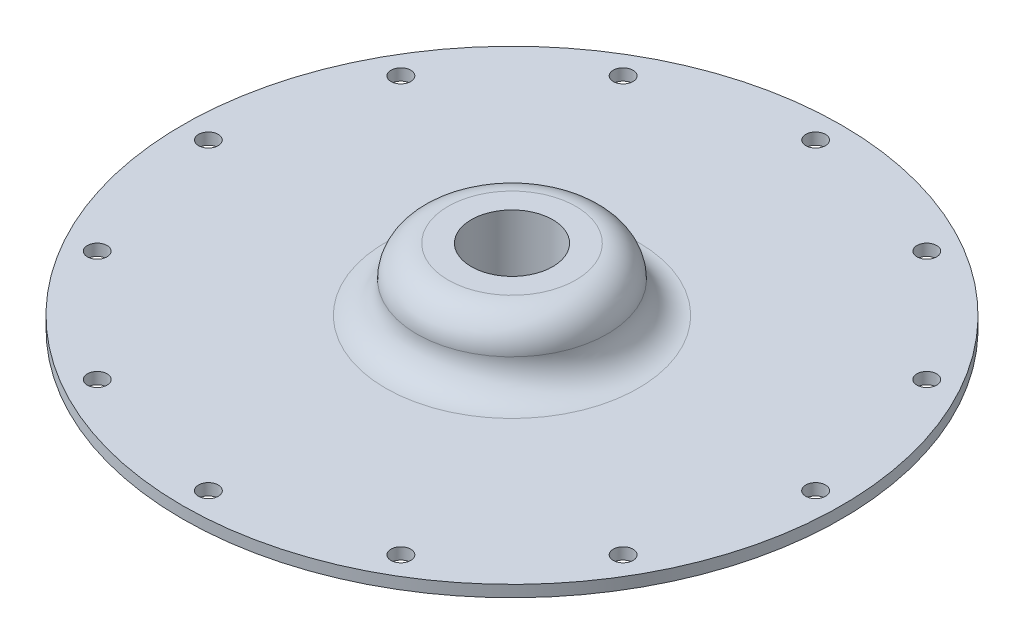
from build123d import *

# Parameters (mm, degrees)
F_36_0_1065_DIAMETER_HOLE1_D = 2.7051
CIRPATTERN1_COUNT            = 12


with BuildPart() as part:
    # Sketch1 → Revolve1 (revolve)
    with BuildSketch(Plane.XY):
        with BuildLine():
            Line((-45.212, 0), (-5.588, 0))
            Line((-5.588, 0), (-5.588, 10.16))
            Line((-5.588, 10.16), (-8.763, 10.16))
            ThreePointArc((-8.763, 10.16), (-11.793836441, 8.904586441), (-13.04925, 5.87375))
            ThreePointArc((-13.04925, 5.87375), (-14.304663559, 2.842913559), (-17.3355, 1.5875))
            Line((-17.3355, 1.5875), (-45.212, 1.5875))
            Line((-45.212, 1.5875), (-45.212, 0))
        make_face()
    revolve(axis=Axis((0, 55, 0), (0, -1, 0)))

    # #36 (0.1065) Diameter Hole1 (through all)
    with Locations(Plane(origin=(0, 0, 0), x_dir=(-1, 0, 0), z_dir=(0, -1, 0))):
        with Locations((41.656, 0)):
            f_36_0_1065_diameter_hole1 = Hole(F_36_0_1065_DIAMETER_HOLE1_D / 2)

    # CirPattern1: #36 (0.1065) Diameter Hole1 ×12 about axis
    cirpattern1_axis = Axis((0, 0, 0), (0, 1, 0))
    for i in range(1, CIRPATTERN1_COUNT):
        add(f_36_0_1065_diameter_hole1.rotate(cirpattern1_axis, i * 360 / CIRPATTERN1_COUNT), mode=Mode.SUBTRACT)


solid = part.part
